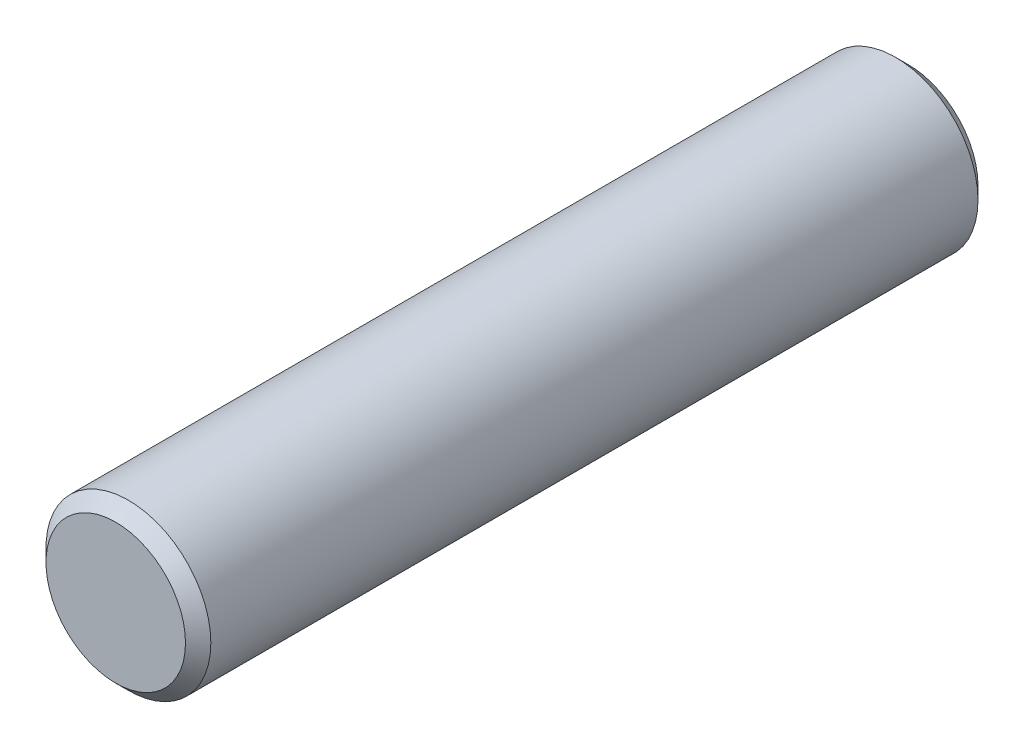
from build123d import *

# Parameters (mm, degrees)
SKETCH1_R           = 1.651
BOSS_EXTRUDE1_DEPTH = 15.875
CHAMFER1_SIZE       = 0.254


with BuildPart() as part:
    # Sketch1 → Boss-Extrude1 (new body)
    with BuildSketch(Plane.XY):
        Circle(SKETCH1_R)
    extrude(amount=-BOSS_EXTRUDE1_DEPTH)

    # Chamfer1
    chamfer1_edges = [part.edges().sort_by_distance(p)[0] for p in [
        (-1.651, 0, -15.875),
        (-1.651, 0, 0),
    ]]
    chamfer(chamfer1_edges, length=CHAMFER1_SIZE)


solid = part.part
